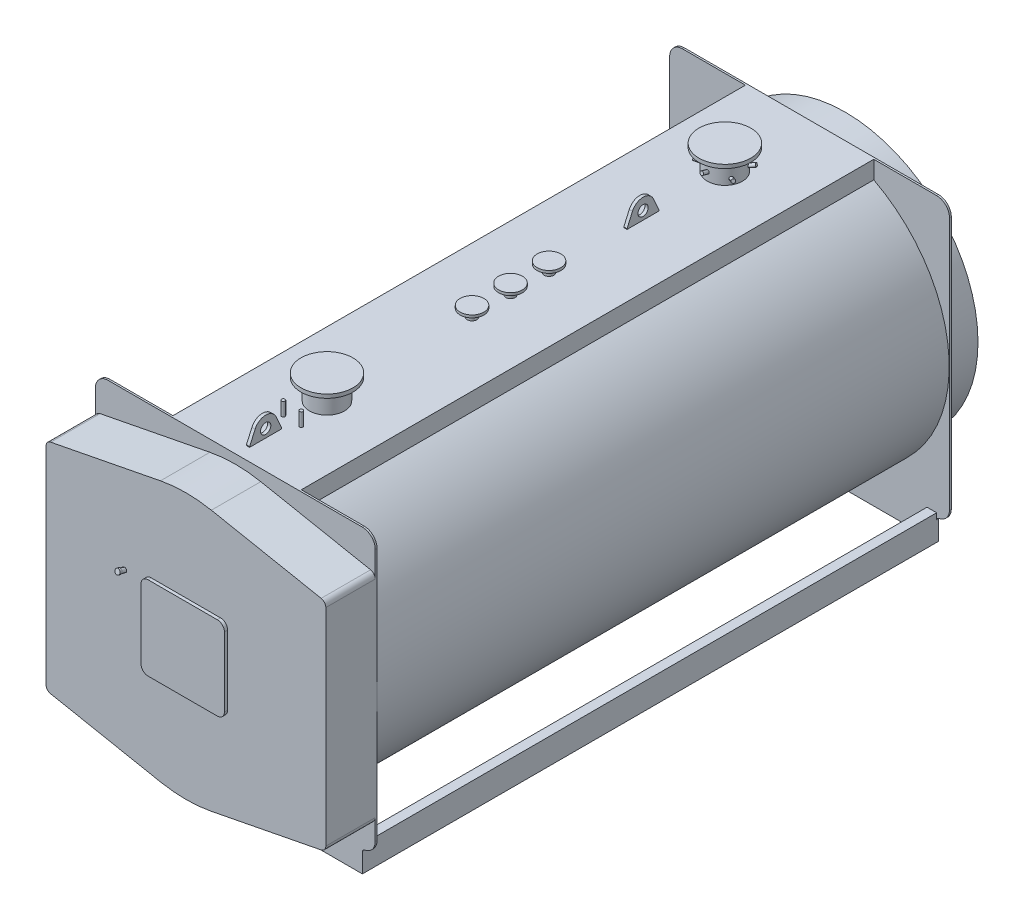
from build123d import *

# Parameters (mm, degrees)
PIASTRA_ANTERIORE_DEPTH       = 14
CORPO_DEPTH                   = 4460
PIASTRA_POSTERIORE_DEPTH      = 14
BASAMENTO_DEPTH               = 4460
SCHIZZO25_R                   = 81
ESTRUSIONE_ESTRUSIONE13_DEPTH = 8
SCHIZZO39_R                   = 13.35
ESTRUSIONE_ESTRUSIONE20_DEPTH = 298
SCHIZZO11_R                   = 21.2
SCHIZZO21_R                   = 136.55
ESTRUSIONE_ESTRUSIONE9_DEPTH  = 1294
SCHIZZO22_R                   = 202.5
ESTRUSIONE_ESTRUSIONE10_DEPTH = 29
SCHIZZO21_4_R                 = 36.5
ESTRUSIONE_ESTRUSIONE11_DEPTH = 1185
SCHIZZO35_R                   = 92.5
ESTRUSIONE_ESTRUSIONE16_DEPTH = 20
SCHIZZO21_6_R                 = 13.35
ESTRUSIONE_ESTRUSIONE18_DEPTH = 1210
RIPETIZIONECIRCOLARE1_COUNT   = 3
ESTRUSIONE_ESTRUSIONE5_DEPTH  = 385
ESTRUSIONE_ESTRUSIONE6_DEPTH  = 25
SCHIZZO37_R                   = 40
ESTRUSIONE_ESTRUSIONE17_DEPTH = 12.5


with BuildPart() as part:
    # Schizzo1 → piastra anteriore (new body)
    with BuildSketch(Plane.XY):
        with BuildLine():
            Line((-990, 2340), (990, 2340))
            ThreePointArc((990, 2340), (1060.710678119, 2310.710678119), (1090, 2240))
            Line((1090, 2240), (1090, 268.601329718))
            ThreePointArc((1090, 268.601329718), (1066.376261583, 204.051607282), (1006.666666667, 170))
            ThreePointArc((1006.666666667, 170), (994.724747683, 163.189678544), (990, 150.279734056))
            Line((990, 150.279734056), (990, 0))
            Line((990, 0), (-990, 0))
            Line((-990, 0), (-990, 150.279734056))
            ThreePointArc((-990, 150.279734056), (-994.724747683, 163.189678544), (-1006.666666667, 170))
            ThreePointArc((-1006.666666667, 170), (-1066.376261583, 204.051607282), (-1090, 268.601329718))
            Line((-1090, 268.601329718), (-1090, 2240))
            ThreePointArc((-1090, 2240), (-1060.710678119, 2310.710678119), (-990, 2340))
        make_face()
    extrude(amount=-PIASTRA_ANTERIORE_DEPTH)

    # Schizzo2 → corpo (add)
    with BuildSketch(Plane(origin=(0, 0, -14), x_dir=(-1, 0, 0), z_dir=(0, 0, -1))):
        with BuildLine():
            Line((500, 2200.741295586), (500, 2340))
            Line((500, 2340), (-500, 2340))
            Line((-500, 2340), (-500, 2200.741295586))
            ThreePointArc((-500, 2200.741295586), (0, 147.5), (500, 2200.741295586))
        make_face()
    extrude(amount=CORPO_DEPTH)

    # Schizzo3 → piastra posteriore (add)
    with BuildSketch(Plane(origin=(0, 0, -4474), x_dir=(-1, 0, 0), z_dir=(0, 0, -1))):
        with BuildLine():
            Line((-990, 150.279734056), (-990, 0))
            Line((-990, 0), (990, 0))
            Line((990, 0), (990, 150.279734056))
            ThreePointArc((990, 150.279734056), (994.724747683, 163.189678544), (1006.666666667, 170))
            ThreePointArc((1006.666666667, 170), (1066.376261583, 204.051607282), (1090, 268.601329718))
            Line((1090, 268.601329718), (1090, 2240))
            ThreePointArc((1090, 2240), (1060.710678119, 2310.710678119), (990, 2340))
            Line((990, 2340), (-990, 2340))
            ThreePointArc((-990, 2340), (-1060.710678119, 2310.710678119), (-1090, 2240))
            Line((-1090, 2240), (-1090, 268.601329718))
            ThreePointArc((-1090, 268.601329718), (-1066.376261583, 204.051607282), (-1006.666666667, 170))
            ThreePointArc((-1006.666666667, 170), (-994.724747683, 163.189678544), (-990, 150.279734056))
        make_face()
    extrude(amount=PIASTRA_POSTERIORE_DEPTH)

    # Schizzo4 → basamento (add)
    with BuildSketch(Plane(origin=(0, 0, -14), x_dir=(-1, 0, 0), z_dir=(0, 0, -1))):
        Polygon((-915, 0), (-990, 0), (-990, 200), (-915, 200), (-915, 192), (-982, 192), (-982, 8), (-915, 8), align=None)
    extrude(amount=BASAMENTO_DEPTH)

    # Schizzo23 → camera-fumo (revolve)
    with BuildSketch(Plane(origin=(0, 0, 0), x_dir=(0, 0, -1), z_dir=(1, 0, 0))):
        Polygon((4488, 2270), (4751, 2270), (4751, 1559), (4796, 1559), (4796, 1600), (4801, 1600), (4801, 1554), (4746, 1554), (4746, 2265), (4488, 2265), align=None)
    revolve(axis=Axis((0, 1235, -4219.232253574), (0, 0, 1)))

    # Schizzo25 → Estrusione-Estrusione13 (add)
    with BuildSketch(Plane(origin=(0, 0, -4751), x_dir=(-1, 0, 0), z_dir=(0, 0, -1))):
        with Locations(Location((0, 394.5, 0), (0, 0, 270))):  # turned: the seam where the file's is
            Circle(SCHIZZO25_R)
    extrude(amount=ESTRUSIONE_ESTRUSIONE13_DEPTH)

    # Schizzo39 → Estrusione-Estrusione20 (add)
    with BuildSketch(Plane(origin=(0, 0, -4488), x_dir=(-1, 0, 0), z_dir=(0, 0, -1))):
        with Locations(Location((0, 215, 0), (0, 0, 270))):  # turned: the seam where the file's is
            Circle(SCHIZZO39_R)
    extrude(amount=ESTRUSIONE_ESTRUSIONE20_DEPTH)

    # Sweep1: sweep along a path in Schizzo10
    with BuildLine(Plane(origin=(0, 0, 0), x_dir=(0, 0, -1), z_dir=(1, 0, 0))) as sweep1_path:
        Line((4344, 410), (4344, 210))
        ThreePointArc((4344, 210), (4361.573593129, 167.573593129), (4404, 150))
        Line((4404, 150), (4899, 150))
    # Schizzo11 → Sweep1 (sweep)
    with BuildSketch(Plane(origin=(0, 150, -4899), x_dir=(-1, 0, 0), z_dir=(0, 0, -1))):
        Circle(SCHIZZO11_R)
    sweep(path=sweep1_path.line)

    # Schizzo21 → Estrusione-Estrusione9 (add)
    with BuildSketch(Plane(origin=(0, 1235, 0), x_dir=(1, 0, 0), z_dir=(0, 1, 0))):
        with Locations(Location((0, 714, 0), (0, 0, 180))):  # turned: the seam where the file's is
            Circle(SCHIZZO21_R)
        with Locations(Location((0, 3814, 0), (0, 0, 180))):  # turned: the seam where the file's is
            Circle(SCHIZZO21_R)
    extrude(amount=ESTRUSIONE_ESTRUSIONE9_DEPTH)

    # Schizzo22 → Estrusione-Estrusione10 (add)
    with BuildSketch(Plane(origin=(0, 2529, 0), x_dir=(1, 0, 0), z_dir=(0, 1, 0))):
        with Locations(Location((0, 714, 0), (0, 0, 270))):  # turned: the seam where the file's is
            Circle(SCHIZZO22_R)
        with Locations(Location((0, 3814, 0), (0, 0, 270))):  # turned: the seam where the file's is
            Circle(SCHIZZO22_R)
    extrude(amount=-ESTRUSIONE_ESTRUSIONE10_DEPTH)

    # Schizzo21_4 → Estrusione-Estrusione11 (add)
    with BuildSketch(Plane(origin=(0, 1235, 0), x_dir=(1, 0, 0), z_dir=(0, 1, 0))):
        with Locations(Location((0, 2444, 0), (0, 0, 180))):  # turned: the seam where the file's is
            Circle(SCHIZZO21_4_R)
        with Locations(Location((0, 1844, 0), (0, 0, 180))):  # turned: the seam where the file's is
            Circle(SCHIZZO21_4_R)
        with Locations(Location((0, 2144, 0), (0, 0, 180))):  # turned: the seam where the file's is
            Circle(SCHIZZO21_4_R)
    extrude(amount=ESTRUSIONE_ESTRUSIONE11_DEPTH)

    # Schizzo35 → Estrusione-Estrusione16 (add)
    with BuildSketch(Plane(origin=(0, 2420, 0), x_dir=(1, 0, 0), z_dir=(0, 1, 0))):
        with Locations(Location((0, 1844, 0), (0, 0, 270))):  # turned: the seam where the file's is
            Circle(SCHIZZO35_R)
        with Locations(Location((0, 2144, 0), (0, 0, 270))):  # turned: the seam where the file's is
            Circle(SCHIZZO35_R)
        with Locations(Location((0, 2444, 0), (0, 0, 270))):  # turned: the seam where the file's is
            Circle(SCHIZZO35_R)
    extrude(amount=-ESTRUSIONE_ESTRUSIONE16_DEPTH)

    # Schizzo21_6 → Estrusione-Estrusione18 (add)
    with BuildSketch(Plane(origin=(0, 1235, 0), x_dir=(1, 0, 0), z_dir=(0, 1, 0))):
        with Locations(Location((-70, 444, 0), (0, 0, 180))):  # turned: the seam where the file's is
            Circle(SCHIZZO21_6_R)
        with Locations(Location((70, 444, 0), (0, 0, 180))):  # turned: the seam where the file's is
            Circle(SCHIZZO21_6_R)
    extrude(amount=ESTRUSIONE_ESTRUSIONE18_DEPTH)

    # Schizzo9 → Rivoluzione3 (revolve)
    with BuildSketch(Plane(origin=(0, 0, 0), x_dir=(0, 0, -1), z_dir=(1, 0, 0))):
        Polygon((3932.55, 2393.101379163), (3990.505549577, 2408.630521869), (3993.986665734, 2395.638819505), (3936.031116157, 2380.109676799), align=None)
    rivoluzione3 = revolve(axis=Axis((0, 2384, -3950.55), (0, -0.258819045, 0.965925826)))

    # Schizzo34 → Rivoluzione5 (revolve)
    with BuildSketch(Plane(origin=(0, 0, 0), x_dir=(0, 0, -1), z_dir=(1, 0, 0))):
        Polygon((3637.494450423, 2428.630521869), (3695.45, 2413.101379163), (3691.968883843, 2400.109676799), (3634.013334266, 2415.638819505), align=None)
    rivoluzione5 = revolve(axis=Axis((0, 2404, -3677.45), (0, 0.258819045, 0.965925826)))

    # RipetizioneCircolare1: Rivoluzione3, Rivoluzione5 ×3 about axis
    ripetizionecircolare1_axis = Axis((0, 0, -3814), (0, 1, 0))
    add([rivoluzione3.rotate(ripetizionecircolare1_axis, i * 360 / RIPETIZIONECIRCOLARE1_COUNT) for i in range(1, RIPETIZIONECIRCOLARE1_COUNT)])
    add([rivoluzione5.rotate(ripetizionecircolare1_axis, i * 360 / RIPETIZIONECIRCOLARE1_COUNT) for i in range(1, RIPETIZIONECIRCOLARE1_COUNT)])

    # Schizzo33 → Rivoluzione4 (revolve)
    with BuildSketch(Plane(origin=(0, 0, 0), x_dir=(0, 0, -1), z_dir=(1, 0, 0))):
        Polygon((832.55, 2413.101379163), (890.505549577, 2428.630521869), (893.986665734, 2415.638819505), (836.031116157, 2400.109676799), align=None)
    revolve(axis=Axis((0, 2428.927708421, -943.581474343), (0, -0.258819045, 0.965925826)))

    # Schizzo14 → Estrusione-Estrusione5 (add)
    with BuildSketch(Plane.XY):
        with BuildLine():
            Line((-1090, 2039.75), (-1090, 430.25))
            ThreePointArc((-1090, 430.25), (-1079.733611394, 401.639228609), (-1053.618833797, 386.08309266))
            Line((-1053.618833797, 386.08309266), (-198.233177338, 219.161131182))
            ThreePointArc((-198.233177338, 219.161131182), (0, 200), (198.233177338, 219.161131182))
            Line((198.233177338, 219.161131182), (1053.618833797, 386.08309266))
            ThreePointArc((1053.618833797, 386.08309266), (1079.733611394, 401.639228609), (1090, 430.25))
            Line((1090, 430.25), (1090, 2039.75))
            ThreePointArc((1090, 2039.75), (1079.733611394, 2068.360771391), (1053.618833797, 2083.91690734))
            Line((1053.618833797, 2083.91690734), (198.233177338, 2250.838868818))
            ThreePointArc((198.233177338, 2250.838868818), (0, 2270), (-198.233177338, 2250.838868818))
            Line((-198.233177338, 2250.838868818), (-1053.618833797, 2083.91690734))
            ThreePointArc((-1053.618833797, 2083.91690734), (-1079.733611394, 2068.360771391), (-1090, 2039.75))
        make_face()
    extrude(amount=ESTRUSIONE_ESTRUSIONE5_DEPTH)

    # Schizzo15 → Estrusione-Estrusione6 (add)
    with BuildSketch(Plane.XY.offset(385)):
        with BuildLine():
            Line((-270, 1560), (270, 1560))
            ThreePointArc((270, 1560), (308.890872965, 1543.890872965), (325, 1505))
            Line((325, 1505), (325, 965))
            ThreePointArc((325, 965), (308.890872965, 926.109127035), (270, 910))
            Line((270, 910), (-270, 910))
            ThreePointArc((-270, 910), (-308.890872965, 926.109127035), (-325, 965))
            Line((-325, 965), (-325, 1505))
            ThreePointArc((-325, 1505), (-308.890872965, 1543.890872965), (-270, 1560))
        make_face()
    extrude(amount=ESTRUSIONE_ESTRUSIONE6_DEPTH)

    # Schizzo18 → Rivoluzione2 (revolve)
    with BuildSketch(Plane(origin=(-478, 0, 0), x_dir=(0, 0, -1), z_dir=(1, 0, 0))):
        Polygon((-420.241857968, 1537.687431022), (-419.426577976, 1540.730097375), (-434.881391196, 1544.871202097), (-440.057772098, 1525.552685571), (-365, 1505.441016151), (-360.63889909, 1521.716866324), align=None)
    revolve(axis=Axis((-478, 1510.8, 385), (0, 0.258819045, 0.965925826)))

    # Schizzo37 → Estrusione-Estrusione17 (add, symmetric)
    with BuildSketch(Plane(origin=(0, 0, 0), x_dir=(0, 0, -1), z_dir=(1, 0, 0))):
        with BuildLine():
            Line((99, 2265), (99, 2345))
            Line((99, 2345), (141.707899924, 2441.441875159))
            ThreePointArc((141.707899924, 2441.441875159), (224, 2495), (306.292100076, 2441.441875159))
            Line((306.292100076, 2441.441875159), (349, 2345))
            Line((349, 2345), (349, 2265))
            Line((349, 2265), (99, 2265))
        make_face()
        with Locations((224, 2405)):
            Circle(SCHIZZO37_R, mode=Mode.SUBTRACT)
        with BuildLine():
            Line((3039, 2265), (3039, 2345))
            Line((3039, 2345), (3081.707899924, 2441.441875159))
            ThreePointArc((3081.707899924, 2441.441875159), (3164, 2495), (3246.292100076, 2441.441875159))
            Line((3246.292100076, 2441.441875159), (3289, 2345))
            Line((3289, 2345), (3289, 2265))
            Line((3289, 2265), (3039, 2265))
        make_face()
        with Locations((3164, 2405)):
            Circle(SCHIZZO37_R, mode=Mode.SUBTRACT)
    extrude(amount=ESTRUSIONE_ESTRUSIONE17_DEPTH, both=True)


solid = part.part
